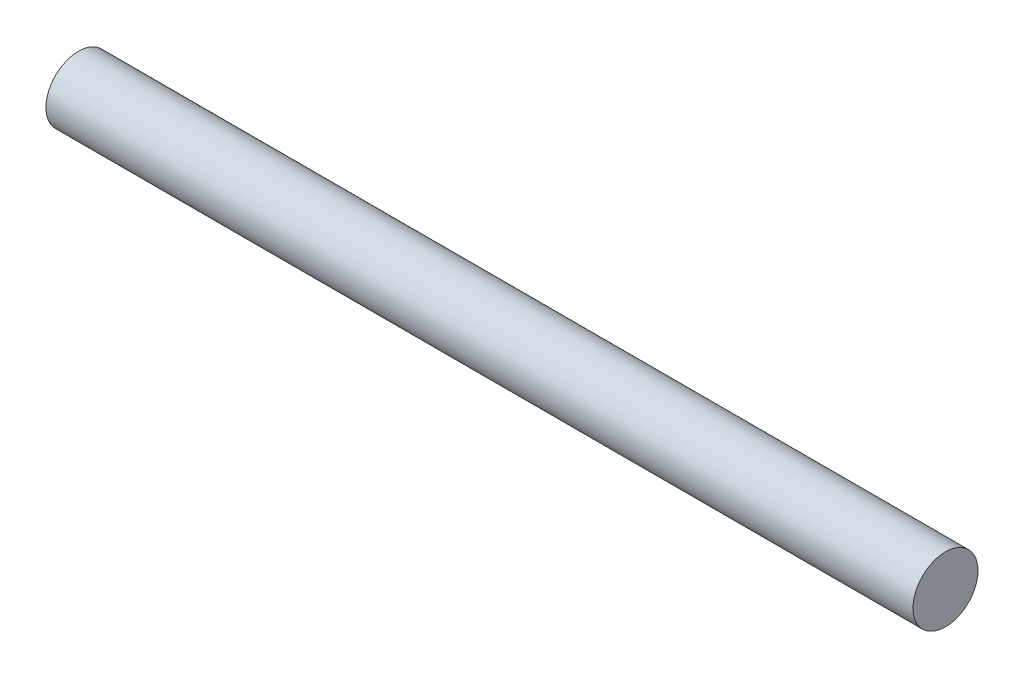
from build123d import *

# Parameters (mm, degrees)
SKETCH1_R           = 1.5
BOSS_EXTRUDE1_DEPTH = 40


with BuildPart() as part:
    # Sketch1 → Boss-Extrude1 (new body)
    with BuildSketch(Plane(origin=(0, 0, 0), x_dir=(0, 0, -1), z_dir=(1, 0, 0))):
        Circle(SKETCH1_R)
    extrude(amount=BOSS_EXTRUDE1_DEPTH)


solid = part.part
